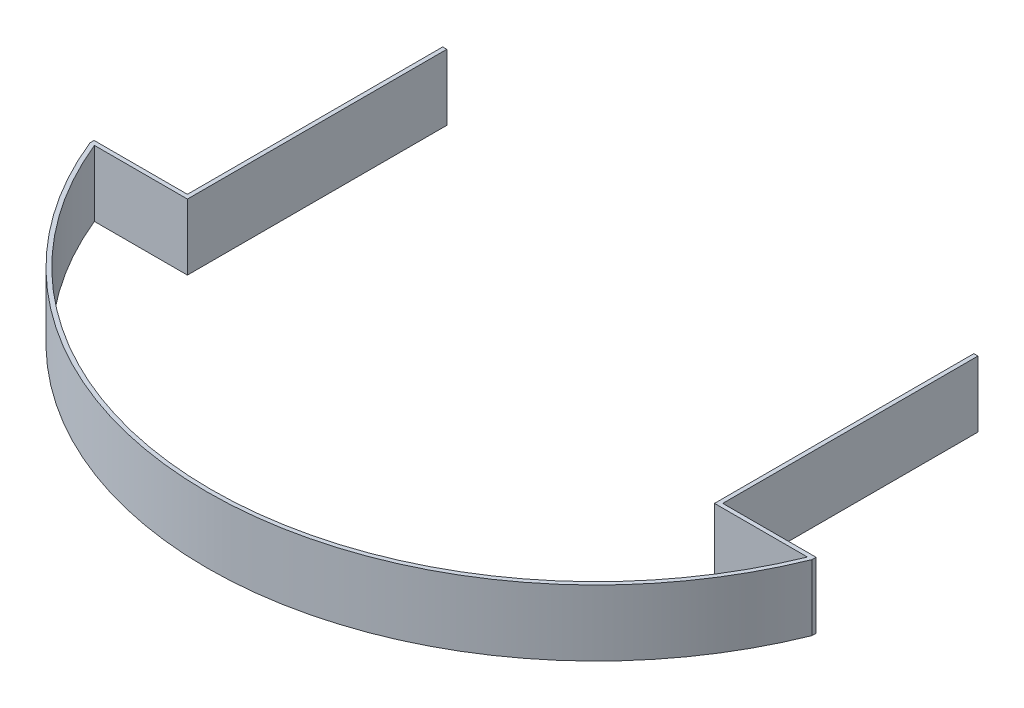
from build123d import *

# Parameters (mm, degrees)
SKETCH1_W           = 1.588
SKETCH1_H           = 1.588
SKETCH1_H_2         = 98.412
SKETCH1_H_3         = 98.4125
SKETCH1_H_4         = 1.5875
BOSS_EXTRUDE1_DEPTH = 25.4


with BuildPart() as part:
    # Sketch1 → Boss-Extrude1 (new body)
    with BuildSketch(Plane(origin=(0, 0, 0), x_dir=(1, 0, 0), z_dir=(0, 1, 0))):
        with BuildLine():
            ThreePointArc((137.441339283, -56), (0, -148.412), (-137.441339283, -56))
            Line((-137.441339283, -56), (-139.154590294, -56))
            ThreePointArc((-139.154590294, -56), (0, -150), (139.154590294, -56))
            Line((139.154590294, -56), (137.441339283, -56))
        make_face()
        with BuildLine():
            Line((103.188, -54.412), (103.188, -56))
            Line((103.188, -56), (137.441339283, -56))
            ThreePointArc((137.441339283, -56), (137.761816422, -55.20691696), (138.077717246, -54.412))
            Line((138.077717246, -54.412), (103.188, -54.412))
        make_face()
        with Locations((102.394, -55.206)):
            Rectangle(SKETCH1_W, SKETCH1_H)
        with Locations((102.394, -5.206)):
            Rectangle(SKETCH1_W, SKETCH1_H_2)
        with Locations((-102.394, -5.20625)):
            Rectangle(SKETCH1_W, SKETCH1_H_3)
        with Locations((-102.394, -55.20625)):
            Rectangle(SKETCH1_W, SKETCH1_H_4)
        with BuildLine():
            Line((-137.441339283, -56), (-103.188, -56))
            Line((-103.188, -56), (-103.188, -54.4125))
            Line((-103.188, -54.4125), (-138.077520211, -54.4125))
            ThreePointArc((-138.077520211, -54.4125), (-137.761716465, -55.207166388), (-137.441339283, -56))
        make_face()
        with BuildLine():
            Line((-139.154590294, -56), (-137.441339283, -56))
            ThreePointArc((-137.441339283, -56), (-137.761716465, -55.207166388), (-138.077520211, -54.4125))
            Line((-138.077520211, -54.4125), (-139.154590294, -54.4125))
            Line((-139.154590294, -54.4125), (-139.154590294, -56))
        make_face()
        with BuildLine():
            ThreePointArc((138.077717246, -54.412), (137.761816422, -55.20691696), (137.441339283, -56))
            Line((137.441339283, -56), (139.154590294, -56))
            Line((139.154590294, -56), (139.154590294, -54.412))
            Line((139.154590294, -54.412), (138.077717246, -54.412))
        make_face()
    extrude(amount=BOSS_EXTRUDE1_DEPTH)


solid = part.part
